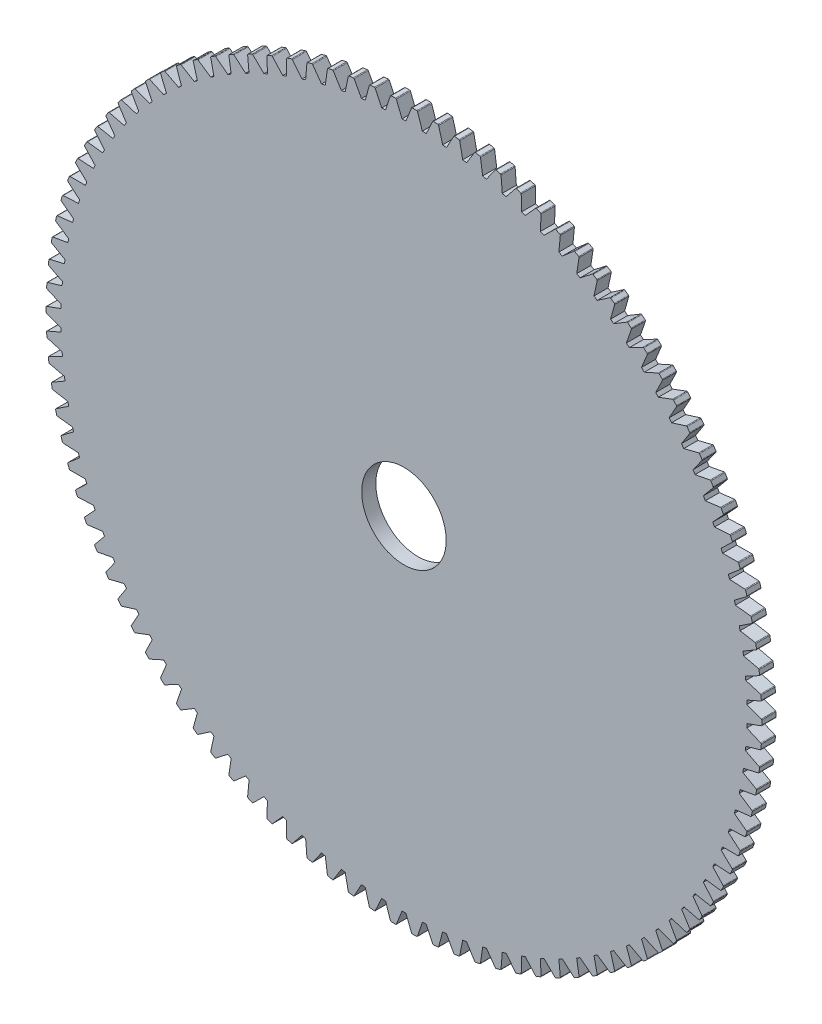
from build123d import *

# Parameters (mm, degrees)
MODEL_R             = 6
BOSS_EXTRUDE1_DEPTH = 2


with BuildPart() as part:
    # Model → Boss-Extrude1 (new body)
    with BuildSketch(Plane.XY):
        with BuildLine():
            Line((102.338378863, 52.221932874), (104.377671973, 52.964174865))
            ThreePointArc((104.377671973, 52.964174865), (104.43377915, 53.007227416), (104.45504553, 53.074675756))
            Line((104.45504553, 53.074675756), (104.45504553, 53.702906161))
            ThreePointArc((104.45504553, 53.702906161), (104.43377915, 53.770354502), (104.377671973, 53.813407053))
            Line((104.377671973, 53.813407053), (102.338378863, 54.555649044))
            ThreePointArc((102.338378863, 54.555649044), (102.330974591, 54.831854463), (102.322003277, 55.108013425))
            Line((102.322003277, 55.108013425), (104.313743959, 55.969760844))
            ThreePointArc((104.313743959, 55.969760844), (104.367202137, 56.016061607), (104.384435485, 56.084651324))
            Line((104.384435485, 56.084651324), (104.347218722, 56.711778388))
            ThreePointArc((104.347218722, 56.711778388), (104.321994009, 56.777848437), (104.263434911, 56.817501552))
            Line((104.263434911, 56.817501552), (102.183752466, 57.437630962))
            ThreePointArc((102.183752466, 57.437630962), (102.159998615, 57.712912657), (102.134683227, 57.988055143))
            Line((102.134683227, 57.988055143), (104.07187542, 58.966281071))
            ThreePointArc((104.07187542, 58.966281071), (104.122496824, 59.015667415), (104.135636608, 59.085157584))
            Line((104.135636608, 59.085157584), (104.061333806, 59.7089785))
            ThreePointArc((104.061333806, 59.7089785), (104.032239364, 59.773438184), (103.971434036, 59.80955258))
            Line((103.971434036, 59.80955258), (101.858667215, 60.305391183))
            ThreePointArc((101.858667215, 60.305391183), (101.818647222, 60.578782216), (101.777076681, 60.851941779))
            Line((101.777076681, 60.851941779), (103.652915926, 61.943210162))
            ThreePointArc((103.652915926, 61.943210162), (103.700522748, 61.995508613), (103.709522814, 62.065655148))
            Line((103.709522814, 62.065655148), (103.598394965, 62.683978722))
            ThreePointArc((103.598394965, 62.683978722), (103.565532988, 62.746601625), (103.502695011, 62.779050449))
            Line((103.502695011, 62.779050449), (101.364264985, 63.148856593))
            ThreePointArc((101.364264985, 63.148856593), (101.308119422, 63.419396669), (101.250439745, 63.689613825))
            Line((101.250439745, 63.689613825), (103.05833709, 64.890091543))
            ThreePointArc((103.05833709, 64.890091543), (103.102762108, 64.945118402), (103.107590843, 65.01567491))
            Line((103.107590843, 65.01567491), (102.960028287, 65.626329259))
            ThreePointArc((102.960028287, 65.626329259), (102.923514205, 65.686895415), (102.858864299, 65.715564689))
            Line((102.858864299, 65.715564689), (100.702282382, 65.958039417))
            ThreePointArc((100.702282382, 65.958039417), (100.630208461, 66.224778253), (100.556622252, 66.491103855))
            Line((100.556622252, 66.491103855), (102.29022739, 67.796574186))
            ThreePointArc((102.29022739, 67.796574186), (102.331314561, 67.854136169), (102.331955003, 67.924854818))
            Line((102.331955003, 67.924854818), (102.14847606, 68.525694996))
            ThreePointArc((102.14847606, 68.525694996), (102.108438128, 68.583991665), (102.04220338, 68.608780686))
            Line((102.04220338, 68.608780686), (99.875044644, 68.723072297))
            ThreePointArc((99.875044644, 68.723072297), (99.787295528, 68.985072964), (99.69806126, 69.246571534))
            Line((99.69806126, 69.246571534), (101.35128484, 70.652448965))
            ThreePointArc((101.35128484, 70.652448965), (101.388889842, 70.712343884), (101.385339743, 70.782976272))
            Line((101.385339743, 70.782976272), (101.166588888, 71.371891806))
            ThreePointArc((101.166588888, 71.371891806), (101.123167743, 71.427714218), (101.055580803, 71.448535915))
            Line((101.055580803, 71.448535915), (98.885457473, 71.434242954))
            ThreePointArc((98.885457473, 71.434242954), (98.782341384, 71.690585165), (98.677772495, 71.946338179))
            Line((98.677772495, 71.946338179), (100.24480751, 73.447684516))
            ThreePointArc((100.24480751, 73.447684516), (100.278798255, 73.509701987), (100.271070083, 73.580000016))
            Line((100.271070083, 73.580000016), (100.017815688, 74.154922318))
            ThreePointArc((100.017815688, 74.154922318), (99.971163848, 74.208074394), (99.902462118, 74.22485563))
            Line((99.902462118, 74.22485563), (97.73699683, 74.082028304))
            ThreePointArc((97.73699683, 74.082028304), (97.618875967, 74.331811647), (97.499339761, 74.580920763))
            Line((97.499339761, 74.580920763), (98.974681942, 76.172462471))
            ThreePointArc((98.974681942, 76.172462471), (99.004939036, 76.236384656), (98.993059938, 76.306101401))
            Line((98.993059938, 76.306101401), (98.706191567, 76.865011036))
            ThreePointArc((98.706191567, 76.865011036), (98.656472897, 76.915306079), (98.586897695, 76.927987909))
            Line((98.586897695, 76.927987909), (96.433696726, 76.657127902))
            ThreePointArc((96.433696726, 76.657127902), (96.300985993, 76.899475004), (96.166902343, 77.141065219))
            Line((96.166902343, 77.141065219), (97.545369498, 78.81721195))
            ThreePointArc((97.545369498, 78.81721195), (97.571786662, 78.882814319), (97.555798363, 78.951704898))
            Line((97.555798363, 78.951704898), (97.236323652, 79.492638675))
            ThreePointArc((97.236323652, 79.492638675), (97.183712792, 79.539900021), (97.113508503, 79.5484379))
            Line((97.113508503, 79.5484379), (94.980135049, 79.150496618))
            ThreePointArc((94.980135049, 79.150496618), (94.833300597, 79.384556227), (94.685140478, 79.617778944))
            Line((94.685140478, 79.617778944), (95.96189069, 81.372643172))
            ThreePointArc((95.96189069, 81.372643172), (95.984375133, 81.439695296), (95.964333793, 81.507517727))
            Line((95.964333793, 81.507517727), (95.613374909, 82.028575597))
            ThreePointArc((95.613374909, 82.028575597), (95.558056655, 82.072637239), (95.487469875, 82.077001177))
            Line((95.487469875, 82.077001177), (93.381417488, 81.553376404))
            ThreePointArc((93.381417488, 81.553376404), (93.220975079, 81.778326376), (93.059258909, 82.002362393))
            Line((93.059258909, 82.002362393), (94.229807546, 83.829780092))
            ThreePointArc((94.229807546, 83.829780092), (94.24828029, 83.898046447), (94.224256304, 83.964562503))
            Line((94.224256304, 83.964562503), (93.843046003, 84.46391423))
            ThreePointArc((93.843046003, 84.46391423), (93.785214664, 84.504621401), (93.71449333, 84.504796069))
            Line((93.71449333, 84.504796069), (91.643159597, 83.857327056))
            ThreePointArc((91.643159597, 83.857327056), (91.46967279, 84.072377246), (91.294968602, 84.286439629))
            Line((91.294968602, 84.286439629), (92.35520407, 86.179991929))
            ThreePointArc((92.35520407, 86.179991929), (92.36960023, 86.249232727), (92.341677984, 86.314208766))
            Line((92.341677984, 86.314208766), (91.93155528, 86.79010036))
            ThreePointArc((91.93155528, 86.79010036), (91.87141399, 86.827310073), (91.800806514, 86.823294858))
            Line((91.800806514, 86.823294858), (89.771467069, 86.054255863))
            ThreePointArc((89.771467069, 86.054255863), (89.585545243, 86.258650901), (89.398466693, 86.461987747))
            Line((89.398466693, 86.461987747), (90.344664876, 88.415023476))
            ThreePointArc((90.344664876, 88.415023476), (90.354933884, 88.484995506), (90.323211455, 88.548203298))
            Line((90.323211455, 88.548203298), (89.88561692, 88.998963173))
            ThreePointArc((89.88561692, 88.998963173), (89.823376928, 89.032544727), (89.753131322, 89.024353733))
            Line((89.753131322, 89.024353733), (87.772914294, 88.136446034))
            ThreePointArc((87.772914294, 88.136446034), (87.575210506, 88.329467973), (87.376414714, 88.521365055))
            Line((87.376414714, 88.521365055), (88.205252056, 90.527024103))
            ThreePointArc((88.205252056, 90.527024103), (88.211357842, 90.597481586), (88.175946657, 90.658699112))
            Line((88.175946657, 90.658699112), (87.712417357, 91.082743956))
            ThreePointArc((87.712417357, 91.082743956), (87.648297282, 91.112579397), (87.578660286, 91.100241394))
            Line((87.578660286, 91.100241394), (85.65452126, 90.096583799))
            ThreePointArc((85.65452126, 90.096583799), (85.445729952, 90.277554644), (85.235915196, 90.457337914))
            Line((85.235915196, 90.457337914), (85.944480376, 92.508575332))
            ThreePointArc((85.944480376, 92.508575332), (85.946401492, 92.579270784), (85.907425934, 92.638283014))
            Line((85.907425934, 92.638283014), (85.419590034, 93.034123356))
            ThreePointArc((85.419590034, 93.034123356), (85.3538151, 93.060107883), (85.285031317, 93.04366621))
            Line((85.285031317, 93.04366621), (83.423728901, 91.927784103))
            ThreePointArc((83.423728901, 91.927784103), (83.20458346, 92.096068186), (82.984486721, 92.263106151))
            Line((82.984486721, 92.263106151), (83.570290877, 94.352716892))
            ThreePointArc((83.570290877, 94.352716892), (83.568020577, 94.423401992), (83.525617549, 94.480001644))
            Line((83.525617549, 94.480001644), (83.015188589, 94.846247079))
            ThreePointArc((83.015188589, 94.846247079), (82.947989834, 94.868289422), (82.880300868, 94.847801831))
            Line((82.880300868, 94.847801831), (81.088372956, 93.623614788))
            ThreePointArc((81.088372956, 93.623614788), (80.859643138, 93.778621005), (80.630037514, 93.932326938))
            Line((80.630037514, 93.932326938), (81.091022989, 96.052971168))
            ThreePointArc((81.091022989, 96.052971168), (81.084569247, 96.123397632), (81.03888769, 96.177385898))
            Line((81.03888769, 96.177385898), (80.507658571, 96.512749975))
            ThreePointArc((80.507658571, 96.512749975), (80.439272033, 96.53077271), (80.372915645, 96.506311164))
            Line((80.372915645, 96.506311164), (78.656656447, 95.178119187))
            ThreePointArc((78.656656447, 95.178119187), (78.419145675, 95.319303074), (78.180837664, 95.459137076))
            Line((78.180837664, 95.459137076), (78.515385229, 97.603365955))
            ThreePointArc((78.515385229, 97.603365955), (78.504770713, 97.673286407), (78.455971087, 97.724473652))
            Line((78.455971087, 97.724473652), (77.90580777, 98.027778393))
            ThreePointArc((77.90580777, 98.027778393), (77.836473659, 98.041718214), (77.771682928, 98.013368634))
            Line((77.771682928, 98.013368634), (76.137120869, 96.585837046))
            ThreePointArc((76.137120869, 96.585837046), (75.891663407, 96.712702689), (75.645490074, 96.838173589))
            Line((75.645490074, 96.838173589), (75.852424619, 98.998455435))
            ThreePointArc((75.852424619, 98.998455435), (75.837686614, 99.067624277), (75.785940329, 99.115830703))
            Line((75.785940329, 99.115830703), (75.218775282, 99.386010739))
            ThreePointArc((75.218775282, 99.386010739), (75.148737137, 99.395818682), (75.085739643, 99.363680648))
            Line((75.085739643, 99.363680648), (73.538616181, 97.841823706))
            ThreePointArc((73.538616181, 97.841823706), (73.286074208, 97.953925484), (73.032900246, 98.064592561))
            Line((73.032900246, 98.064592561), (73.111494906, 100.233339305))
            ThreePointArc((73.111494906, 100.233339305), (73.092685179, 100.301513579), (73.038173995, 100.346569859))
            Line((73.038173995, 100.346569859), (72.455999408, 100.582676173))
            ThreePointArc((72.455999408, 100.582676173), (72.38550324, 100.588317787), (72.324520263, 100.552504185))
            Line((72.324520263, 100.552504185), (70.870269725, 98.941667467))
            ThreePointArc((70.870269725, 98.941667467), (70.611530304, 99.038611619), (70.352244997, 99.134086151))
            Line((70.352244997, 99.134086151), (70.302223704, 101.30367999))
            ThreePointArc((70.302223704, 101.30367999), (70.279408325, 101.370620232), (70.222323716, 101.412368105))
            Line((70.222323716, 101.412368105), (69.627184497, 101.613571365))
            ThreePointArc((69.627184497, 101.613571365), (69.556477926, 101.615026833), (69.497723672, 101.575663459))
            Line((69.497723672, 101.575663459), (68.141454167, 99.881505087))
            ThreePointArc((68.141454167, 99.881505087), (67.87742613, 99.962951094), (67.612940226, 100.042897722))
            Line((67.612940226, 100.042897722), (67.434478682, 102.205717881))
            ThreePointArc((67.434478682, 102.205717881), (67.407737791, 102.27118896), (67.348280267, 102.309481784))
            Line((67.348280267, 102.309481784), (66.742266865, 102.475075256))
            ThreePointArc((66.742266865, 102.475075256), (66.671598251, 102.472339466), (66.615279097, 102.429564586))
            Line((66.615279097, 102.429564586), (65.36175457, 100.658035354))
            ThreePointArc((65.36175457, 100.658035354), (65.093365324, 100.723697133), (64.82460784, 100.787835042))
            Line((64.82460784, 100.787835042), (64.518332899, 102.936284534))
            ThreePointArc((64.518332899, 102.936284534), (64.487760424, 103.000056482), (64.426138833, 103.034759752))
            Line((64.426138833, 103.034759752), (63.811379891, 103.164161783))
            ThreePointArc((63.811379891, 103.164161783), (63.740997461, 103.157244345), (63.687311228, 103.111208207))
            Line((63.687311228, 103.111208207), (62.540934731, 101.268530676))
            ThreePointArc((62.540934731, 101.268530676), (62.269127003, 101.318177588), (61.99704196, 101.366281491))
            Line((61.99704196, 101.366281491), (61.564029423, 103.49281381))
            ThreePointArc((61.564029423, 103.49281381), (61.529732751, 103.554662624), (61.46616354, 103.585654445))
            Line((61.46616354, 103.585654445), (60.844818423, 103.678410505))
            ThreePointArc((60.844818423, 103.678410505), (60.774969396, 103.667335716), (60.72410466, 103.618200025))
            Line((60.72410466, 103.618200025), (59.688902882, 101.710846665))
            ThreePointArc((59.688902882, 101.710846665), (59.414631407, 101.744304323), (59.140174512, 101.776205255))
            Line((59.140174512, 101.776205255), (58.581945352, 103.873350878))
            ThreePointArc((58.581945352, 103.873350878), (58.544044952, 103.933059313), (58.47875141, 103.960230823))
            Line((58.47875141, 103.960230823), (57.853002614, 104.016015104))
            ThreePointArc((57.853002614, 104.016015104), (57.783932338, 104.000821866), (57.736067764, 103.94875921))
            Line((57.736067764, 103.94875921), (56.815676889, 101.983429672))
            ThreePointArc((56.815676889, 101.983429672), (56.539905056, 102.000580555), (56.264040349, 102.016166461))
            Line((56.264040349, 102.016166461), (55.582555365, 104.076559088))
            ThreePointArc((55.582555365, 104.076559088), (55.541184364, 104.133917415), (55.474395838, 104.157173175))
            Line((55.474395838, 104.157173175), (54.846441329, 104.175789732))
            ThreePointArc((54.846441329, 104.175789732), (54.778392416, 104.156531411), (54.733696129, 104.101724664))
            Line((54.733696129, 104.101724664), (53.931349063, 102.085322238))
            ThreePointArc((53.931349063, 102.085322238), (53.65504553, 102.086106103), (53.378741997, 102.085322238))
            Line((53.378741997, 102.085322238), (52.576394931, 104.101724664))
            ThreePointArc((52.576394931, 104.101724664), (52.531698644, 104.156531411), (52.463649731, 104.175789732))
            Line((52.463649731, 104.175789732), (51.835695222, 104.157173175))
            ThreePointArc((51.835695222, 104.157173175), (51.768906696, 104.133917415), (51.727535694, 104.076559088))
            Line((51.727535694, 104.076559088), (51.046050711, 102.016166461))
            ThreePointArc((51.046050711, 102.016166461), (50.770186004, 102.000580555), (50.494414171, 101.983429672))
            Line((50.494414171, 101.983429672), (49.574023295, 103.94875921))
            ThreePointArc((49.574023295, 103.94875921), (49.526158721, 104.000821866), (49.457088446, 104.016015104))
            Line((49.457088446, 104.016015104), (48.83133965, 103.960230823))
            ThreePointArc((48.83133965, 103.960230823), (48.766046108, 103.933059313), (48.728145708, 103.873350878))
            Line((48.728145708, 103.873350878), (48.169916548, 101.776205255))
            ThreePointArc((48.169916548, 101.776205255), (47.895459653, 101.744304323), (47.621188178, 101.710846665))
            Line((47.621188178, 101.710846665), (46.5859864, 103.618200025))
            ThreePointArc((46.5859864, 103.618200025), (46.535121664, 103.667335716), (46.465272637, 103.678410505))
            Line((46.465272637, 103.678410505), (45.84392752, 103.585654445))
            ThreePointArc((45.84392752, 103.585654445), (45.780358309, 103.554662624), (45.746061637, 103.49281381))
            Line((45.746061637, 103.49281381), (45.3130491, 101.366281491))
            ThreePointArc((45.3130491, 101.366281491), (45.040964056, 101.318177588), (44.769156329, 101.268530676))
            Line((44.769156329, 101.268530676), (43.622779832, 103.111208207))
            ThreePointArc((43.622779832, 103.111208207), (43.569093599, 103.157244345), (43.498711169, 103.164161783))
            Line((43.498711169, 103.164161783), (42.883952227, 103.034759752))
            ThreePointArc((42.883952227, 103.034759752), (42.822330636, 103.000056482), (42.791758161, 102.936284534))
            Line((42.791758161, 102.936284534), (42.48548322, 100.787835042))
            ThreePointArc((42.48548322, 100.787835042), (42.216725736, 100.723697133), (41.948336489, 100.658035354))
            Line((41.948336489, 100.658035354), (40.694811963, 102.429564586))
            ThreePointArc((40.694811963, 102.429564586), (40.638492808, 102.472339466), (40.567824195, 102.475075256))
            Line((40.567824195, 102.475075256), (39.961810793, 102.309481784))
            ThreePointArc((39.961810793, 102.309481784), (39.902353268, 102.27118896), (39.875612377, 102.205717881))
            Line((39.875612377, 102.205717881), (39.697150834, 100.042897722))
            ThreePointArc((39.697150834, 100.042897722), (39.43266493, 99.962951094), (39.168636893, 99.881505087))
            Line((39.168636893, 99.881505087), (37.812367388, 101.575663459))
            ThreePointArc((37.812367388, 101.575663459), (37.753613134, 101.615026833), (37.682906563, 101.613571365))
            Line((37.682906563, 101.613571365), (37.087767344, 101.412368105))
            ThreePointArc((37.087767344, 101.412368105), (37.030682734, 101.370620232), (37.007867355, 101.30367999))
            Line((37.007867355, 101.30367999), (36.957846063, 99.134086151))
            ThreePointArc((36.957846063, 99.134086151), (36.698560756, 99.038611619), (36.439821335, 98.941667467))
            Line((36.439821335, 98.941667467), (34.985570797, 100.552504185))
            ThreePointArc((34.985570797, 100.552504185), (34.92458782, 100.588317787), (34.854091652, 100.582676173))
            Line((34.854091652, 100.582676173), (34.271917065, 100.346569859))
            ThreePointArc((34.271917065, 100.346569859), (34.217405881, 100.301513579), (34.198596154, 100.233339305))
            Line((34.198596154, 100.233339305), (34.277190814, 98.064592561))
            ThreePointArc((34.277190814, 98.064592561), (34.024016852, 97.953925484), (33.771474879, 97.841823706))
            Line((33.771474879, 97.841823706), (32.224351417, 99.363680648))
            ThreePointArc((32.224351417, 99.363680648), (32.161353923, 99.395818682), (32.091315777, 99.386010739))
            Line((32.091315777, 99.386010739), (31.524150731, 99.115830703))
            ThreePointArc((31.524150731, 99.115830703), (31.472404446, 99.067624277), (31.457666441, 98.998455435))
            Line((31.457666441, 98.998455435), (31.664600986, 96.838173589))
            ThreePointArc((31.664600986, 96.838173589), (31.418427653, 96.712702689), (31.172970191, 96.585837046))
            Line((31.172970191, 96.585837046), (29.538408132, 98.013368634))
            ThreePointArc((29.538408132, 98.013368634), (29.473617401, 98.041718214), (29.40428329, 98.027778393))
            Line((29.40428329, 98.027778393), (28.854119973, 97.724473652))
            ThreePointArc((28.854119973, 97.724473652), (28.805320347, 97.673286407), (28.794705831, 97.603365955))
            Line((28.794705831, 97.603365955), (29.129253396, 95.459137076))
            ThreePointArc((29.129253396, 95.459137076), (28.890945385, 95.319303074), (28.653434612, 95.178119187))
            Line((28.653434612, 95.178119187), (26.937175415, 96.506311164))
            ThreePointArc((26.937175415, 96.506311164), (26.870819027, 96.53077271), (26.802432489, 96.512749975))
            Line((26.802432489, 96.512749975), (26.27120337, 96.177385898))
            ThreePointArc((26.27120337, 96.177385898), (26.225521813, 96.123397632), (26.219068071, 96.052971168))
            Line((26.219068071, 96.052971168), (26.680053546, 93.932326938))
            ThreePointArc((26.680053546, 93.932326938), (26.450447921, 93.778621005), (26.221718104, 93.623614788))
            Line((26.221718104, 93.623614788), (24.429790192, 94.847801831))
            ThreePointArc((24.429790192, 94.847801831), (24.362101226, 94.868289422), (24.294902471, 94.846247079))
            Line((24.294902471, 94.846247079), (23.784473511, 94.480001644))
            ThreePointArc((23.784473511, 94.480001644), (23.742070483, 94.423401992), (23.739800182, 94.352716892))
            Line((23.739800182, 94.352716892), (24.325604339, 92.263106151))
            ThreePointArc((24.325604339, 92.263106151), (24.1055076, 92.096068186), (23.886362159, 91.927784103))
            Line((23.886362159, 91.927784103), (22.025059743, 93.04366621))
            ThreePointArc((22.025059743, 93.04366621), (21.95627596, 93.060107883), (21.890501026, 93.034123356))
            Line((21.890501026, 93.034123356), (21.402665126, 92.638283014))
            ThreePointArc((21.402665126, 92.638283014), (21.363689567, 92.579270784), (21.365610684, 92.508575332))
            Line((21.365610684, 92.508575332), (22.074175864, 90.457337914))
            ThreePointArc((22.074175864, 90.457337914), (21.864361107, 90.277554644), (21.6555698, 90.096583799))
            Line((21.6555698, 90.096583799), (19.731430774, 91.100241394))
            ThreePointArc((19.731430774, 91.100241394), (19.661793778, 91.112579397), (19.597673703, 91.082743956))
            Line((19.597673703, 91.082743956), (19.134144403, 90.658699112))
            ThreePointArc((19.134144403, 90.658699112), (19.098733218, 90.597481586), (19.104839004, 90.527024103))
            Line((19.104839004, 90.527024103), (19.933676346, 88.521365055))
            ThreePointArc((19.933676346, 88.521365055), (19.734880554, 88.329467973), (19.537176766, 88.136446034))
            Line((19.537176766, 88.136446034), (17.556959738, 89.024353733))
            ThreePointArc((17.556959738, 89.024353733), (17.486714132, 89.032544727), (17.42447414, 88.998963173))
            Line((17.42447414, 88.998963173), (16.986879605, 88.548203298))
            ThreePointArc((16.986879605, 88.548203298), (16.955157176, 88.484995506), (16.965426184, 88.415023476))
            Line((16.965426184, 88.415023476), (17.911624366, 86.461987747))
            ThreePointArc((17.911624366, 86.461987747), (17.724545817, 86.258650901), (17.538623991, 86.054255863))
            Line((17.538623991, 86.054255863), (15.509284545, 86.823294858))
            ThreePointArc((15.509284545, 86.823294858), (15.43867707, 86.827310073), (15.37853578, 86.79010036))
            Line((15.37853578, 86.79010036), (14.968413076, 86.314208766))
            ThreePointArc((14.968413076, 86.314208766), (14.94049083, 86.249232727), (14.95488699, 86.179991929))
            Line((14.95488699, 86.179991929), (16.015122458, 84.286439629))
            ThreePointArc((16.015122458, 84.286439629), (15.84041827, 84.072377246), (15.666931463, 83.857327056))
            Line((15.666931463, 83.857327056), (13.595597729, 84.504796069))
            ThreePointArc((13.595597729, 84.504796069), (13.524876396, 84.504621401), (13.467045057, 84.46391423))
            Line((13.467045057, 84.46391423), (13.085834755, 83.964562503))
            ThreePointArc((13.085834755, 83.964562503), (13.061810769, 83.898046447), (13.080283514, 83.829780092))
            Line((13.080283514, 83.829780092), (14.250832151, 82.002362393))
            ThreePointArc((14.250832151, 82.002362393), (14.089115981, 81.778326376), (13.928673572, 81.553376404))
            Line((13.928673572, 81.553376404), (11.822621185, 82.077001177))
            ThreePointArc((11.822621185, 82.077001177), (11.752034405, 82.072637239), (11.696716151, 82.028575597))
            Line((11.696716151, 82.028575597), (11.345757267, 81.507517727))
            ThreePointArc((11.345757267, 81.507517727), (11.325715926, 81.439695296), (11.34820037, 81.372643172))
            Line((11.34820037, 81.372643172), (12.624950581, 79.617778944))
            ThreePointArc((12.624950581, 79.617778944), (12.476790463, 79.384556227), (12.329956011, 79.150496618))
            Line((12.329956011, 79.150496618), (10.196582557, 79.5484379))
            ThreePointArc((10.196582557, 79.5484379), (10.126378268, 79.539900021), (10.073767407, 79.492638675))
            Line((10.073767407, 79.492638675), (9.754292697, 78.951704898))
            ThreePointArc((9.754292697, 78.951704898), (9.738304398, 78.882814319), (9.764721562, 78.81721195))
            Line((9.764721562, 78.81721195), (11.143188717, 77.141065219))
            ThreePointArc((11.143188717, 77.141065219), (11.009105067, 76.899475004), (10.876394334, 76.657127902))
            Line((10.876394334, 76.657127902), (8.723193364, 76.927987909))
            ThreePointArc((8.723193364, 76.927987909), (8.653618163, 76.915306079), (8.603899493, 76.865011036))
            Line((8.603899493, 76.865011036), (8.317031122, 76.306101401))
            ThreePointArc((8.317031122, 76.306101401), (8.305152024, 76.236384656), (8.335409118, 76.172462471))
            Line((8.335409118, 76.172462471), (9.810751299, 74.580920763))
            ThreePointArc((9.810751299, 74.580920763), (9.691215093, 74.331811647), (9.57309423, 74.082028304))
            Line((9.57309423, 74.082028304), (7.407628942, 74.22485563))
            ThreePointArc((7.407628942, 74.22485563), (7.338927212, 74.208074394), (7.292275372, 74.154922318))
            Line((7.292275372, 74.154922318), (7.039020976, 73.580000016))
            ThreePointArc((7.039020976, 73.580000016), (7.031292805, 73.509701987), (7.06528355, 73.447684516))
            Line((7.06528355, 73.447684516), (8.632318565, 71.946338179))
            ThreePointArc((8.632318565, 71.946338179), (8.527749676, 71.690585165), (8.424633587, 71.434242954))
            Line((8.424633587, 71.434242954), (6.254510256, 71.448535915))
            ThreePointArc((6.254510256, 71.448535915), (6.186923317, 71.427714218), (6.143502172, 71.371891806))
            Line((6.143502172, 71.371891806), (5.924751317, 70.782976272))
            ThreePointArc((5.924751317, 70.782976272), (5.921201217, 70.712343884), (5.95880622, 70.652448965))
            Line((5.95880622, 70.652448965), (7.6120298, 69.246571534))
            ThreePointArc((7.6120298, 69.246571534), (7.522795532, 68.985072964), (7.435046416, 68.723072297))
            Line((7.435046416, 68.723072297), (5.26788768, 68.608780686))
            ThreePointArc((5.26788768, 68.608780686), (5.201652931, 68.583991665), (5.161615, 68.525694996))
            Line((5.161615, 68.525694996), (4.978136057, 67.924854818))
            ThreePointArc((4.978136057, 67.924854818), (4.978776499, 67.854136169), (5.01986367, 67.796574186))
            Line((5.01986367, 67.796574186), (6.753468808, 66.491103855))
            ThreePointArc((6.753468808, 66.491103855), (6.679882599, 66.224778253), (6.607808678, 65.958039417))
            Line((6.607808678, 65.958039417), (4.451226761, 65.715564689))
            ThreePointArc((4.451226761, 65.715564689), (4.386576855, 65.686895415), (4.350062772, 65.626329259))
            Line((4.350062772, 65.626329259), (4.202500217, 65.01567491))
            ThreePointArc((4.202500217, 65.01567491), (4.207328952, 64.945118402), (4.25175397, 64.890091543))
            Line((4.25175397, 64.890091543), (6.059651315, 63.689613825))
            ThreePointArc((6.059651315, 63.689613825), (6.001971638, 63.419396669), (5.945826075, 63.148856593))
            Line((5.945826075, 63.148856593), (3.807396049, 62.779050449))
            ThreePointArc((3.807396049, 62.779050449), (3.744558072, 62.746601625), (3.711696095, 62.683978722))
            Line((3.711696095, 62.683978722), (3.600568246, 62.065655148))
            ThreePointArc((3.600568246, 62.065655148), (3.609568312, 61.995508613), (3.657175133, 61.943210162))
            Line((3.657175133, 61.943210162), (5.533014379, 60.851941779))
            ThreePointArc((5.533014379, 60.851941779), (5.491443838, 60.578782216), (5.451423845, 60.305391183))
            Line((5.451423845, 60.305391183), (3.338657024, 59.80955258))
            ThreePointArc((3.338657024, 59.80955258), (3.277851696, 59.773438184), (3.248757253, 59.7089785))
            Line((3.248757253, 59.7089785), (3.174454451, 59.085157584))
            ThreePointArc((3.174454451, 59.085157584), (3.187594236, 59.015667415), (3.23821564, 58.966281071))
            Line((3.23821564, 58.966281071), (5.175407833, 57.988055143))
            ThreePointArc((5.175407833, 57.988055143), (5.150092445, 57.712912657), (5.126338594, 57.437630962))
            Line((5.126338594, 57.437630962), (3.046656149, 56.817501552))
            ThreePointArc((3.046656149, 56.817501552), (2.988097051, 56.777848437), (2.962872338, 56.711778388))
            Line((2.962872338, 56.711778388), (2.925655574, 56.084651324))
            ThreePointArc((2.925655574, 56.084651324), (2.942888923, 56.016061607), (2.996347101, 55.969760844))
            Line((2.996347101, 55.969760844), (4.988087783, 55.108013425))
            ThreePointArc((4.988087783, 55.108013425), (4.979116469, 54.831854463), (4.971712197, 54.555649044))
            Line((4.971712197, 54.555649044), (2.932419087, 53.813407053))
            ThreePointArc((2.932419087, 53.813407053), (2.87631191, 53.770354502), (2.85504553, 53.702906161))
            Line((2.85504553, 53.702906161), (2.85504553, 53.074675756))
            ThreePointArc((2.85504553, 53.074675756), (2.87631191, 53.007227416), (2.932419087, 52.964174865))
            Line((2.932419087, 52.964174865), (4.971712197, 52.221932874))
            ThreePointArc((4.971712197, 52.221932874), (4.979116469, 51.945727455), (4.988087783, 51.669568493))
            Line((4.988087783, 51.669568493), (2.996347101, 50.807821074))
            ThreePointArc((2.996347101, 50.807821074), (2.942888923, 50.76152031), (2.925655574, 50.692930594))
            Line((2.925655574, 50.692930594), (2.962872338, 50.06580353))
            ThreePointArc((2.962872338, 50.06580353), (2.988097051, 49.999733481), (3.046656149, 49.960080366))
            Line((3.046656149, 49.960080366), (5.126338594, 49.339950955))
            ThreePointArc((5.126338594, 49.339950955), (5.150092445, 49.064669261), (5.175407833, 48.789526774))
            Line((5.175407833, 48.789526774), (3.23821564, 47.811300846))
            ThreePointArc((3.23821564, 47.811300846), (3.187594236, 47.761914503), (3.174454451, 47.692424334))
            Line((3.174454451, 47.692424334), (3.248757253, 47.068603418))
            ThreePointArc((3.248757253, 47.068603418), (3.277851696, 47.004143734), (3.338657024, 46.968029338))
            Line((3.338657024, 46.968029338), (5.451423845, 46.472190735))
            ThreePointArc((5.451423845, 46.472190735), (5.491443838, 46.198799702), (5.533014379, 45.925640139))
            Line((5.533014379, 45.925640139), (3.657175133, 44.834371756))
            ThreePointArc((3.657175133, 44.834371756), (3.609568312, 44.782073305), (3.600568246, 44.71192677))
            Line((3.600568246, 44.71192677), (3.711696095, 44.093603195))
            ThreePointArc((3.711696095, 44.093603195), (3.744558072, 44.030980292), (3.807396049, 43.998531469))
            Line((3.807396049, 43.998531469), (5.945826075, 43.628725325))
            ThreePointArc((5.945826075, 43.628725325), (6.001971638, 43.358185249), (6.059651315, 43.087968093))
            Line((6.059651315, 43.087968093), (4.25175397, 41.887490375))
            ThreePointArc((4.25175397, 41.887490375), (4.207328952, 41.832463516), (4.202500217, 41.761907008))
            Line((4.202500217, 41.761907008), (4.350062772, 41.151252659))
            ThreePointArc((4.350062772, 41.151252659), (4.386576855, 41.090686502), (4.451226761, 41.062017229))
            Line((4.451226761, 41.062017229), (6.607808678, 40.819542501))
            ThreePointArc((6.607808678, 40.819542501), (6.679882599, 40.552803665), (6.753468808, 40.286478062))
            Line((6.753468808, 40.286478062), (5.01986367, 38.981007732))
            ThreePointArc((5.01986367, 38.981007732), (4.978776499, 38.923445749), (4.978136057, 38.852727099))
            Line((4.978136057, 38.852727099), (5.161615, 38.251886922))
            ThreePointArc((5.161615, 38.251886922), (5.201652931, 38.193590253), (5.26788768, 38.168801232))
            Line((5.26788768, 38.168801232), (7.435046416, 38.054509621))
            ThreePointArc((7.435046416, 38.054509621), (7.522795532, 37.792508954), (7.6120298, 37.531010384))
            Line((7.6120298, 37.531010384), (5.95880622, 36.125132953))
            ThreePointArc((5.95880622, 36.125132953), (5.921201217, 36.065238034), (5.924751317, 35.994605645))
            Line((5.924751317, 35.994605645), (6.143502172, 35.405690112))
            ThreePointArc((6.143502172, 35.405690112), (6.186923317, 35.3498677), (6.254510256, 35.329046003))
            Line((6.254510256, 35.329046003), (8.424633587, 35.343338963))
            ThreePointArc((8.424633587, 35.343338963), (8.527749676, 35.086996753), (8.632318565, 34.831243739))
            Line((8.632318565, 34.831243739), (7.06528355, 33.329897402))
            ThreePointArc((7.06528355, 33.329897402), (7.031292805, 33.267879931), (7.039020976, 33.197581902))
            Line((7.039020976, 33.197581902), (7.292275372, 32.6226596))
            ThreePointArc((7.292275372, 32.6226596), (7.338927212, 32.569507523), (7.407628942, 32.552726287))
            Line((7.407628942, 32.552726287), (9.57309423, 32.695553614))
            ThreePointArc((9.57309423, 32.695553614), (9.691215093, 32.445770271), (9.810751299, 32.196661154))
            Line((9.810751299, 32.196661154), (8.335409118, 30.605119447))
            ThreePointArc((8.335409118, 30.605119447), (8.305152024, 30.541197262), (8.317031122, 30.471480517))
            Line((8.317031122, 30.471480517), (8.603899493, 29.912570882))
            ThreePointArc((8.603899493, 29.912570882), (8.653618163, 29.862275839), (8.723193364, 29.849594009))
            Line((8.723193364, 29.849594009), (10.876394334, 30.120454016))
            ThreePointArc((10.876394334, 30.120454016), (11.009105067, 29.878106913), (11.143188717, 29.636516699))
            Line((11.143188717, 29.636516699), (9.764721562, 27.960369968))
            ThreePointArc((9.764721562, 27.960369968), (9.738304398, 27.894767598), (9.754292697, 27.82587702))
            Line((9.754292697, 27.82587702), (10.073767407, 27.284943243))
            ThreePointArc((10.073767407, 27.284943243), (10.126378268, 27.237681897), (10.196582557, 27.229144018))
            Line((10.196582557, 27.229144018), (12.329956011, 27.6270853))
            ThreePointArc((12.329956011, 27.6270853), (12.476790463, 27.393025691), (12.624950581, 27.159802973))
            Line((12.624950581, 27.159802973), (11.34820037, 25.404938746))
            ThreePointArc((11.34820037, 25.404938746), (11.325715926, 25.337886622), (11.345757267, 25.270064191))
            Line((11.345757267, 25.270064191), (11.696716151, 24.749006321))
            ThreePointArc((11.696716151, 24.749006321), (11.752034405, 24.704944679), (11.822621185, 24.700580741))
            Line((11.822621185, 24.700580741), (13.928673572, 25.224205514))
            ThreePointArc((13.928673572, 25.224205514), (14.089115981, 24.999255542), (14.250832151, 24.775219524))
            Line((14.250832151, 24.775219524), (13.080283514, 22.947801825))
            ThreePointArc((13.080283514, 22.947801825), (13.061810769, 22.87953547), (13.085834755, 22.813019415))
            Line((13.085834755, 22.813019415), (13.467045057, 22.313667688))
            ThreePointArc((13.467045057, 22.313667688), (13.524876396, 22.272960517), (13.595597729, 22.272785849))
            Line((13.595597729, 22.272785849), (15.666931463, 22.920254862))
            ThreePointArc((15.666931463, 22.920254862), (15.84041827, 22.705204672), (16.015122458, 22.491142289))
            Line((16.015122458, 22.491142289), (14.95488699, 20.597589989))
            ThreePointArc((14.95488699, 20.597589989), (14.94049083, 20.528349191), (14.968413076, 20.463373152))
            Line((14.968413076, 20.463373152), (15.37853578, 19.987481558))
            ThreePointArc((15.37853578, 19.987481558), (15.43867707, 19.950271845), (15.509284545, 19.95428706))
            Line((15.509284545, 19.95428706), (17.538623991, 20.723326054))
            ThreePointArc((17.538623991, 20.723326054), (17.724545817, 20.518931017), (17.911624366, 20.315594171))
            Line((17.911624366, 20.315594171), (16.965426184, 18.362558442))
            ThreePointArc((16.965426184, 18.362558442), (16.955157176, 18.292586412), (16.986879605, 18.22937862))
            Line((16.986879605, 18.22937862), (17.42447414, 17.778618745))
            ThreePointArc((17.42447414, 17.778618745), (17.486714132, 17.74503719), (17.556959738, 17.753228185))
            Line((17.556959738, 17.753228185), (19.537176766, 18.641135884))
            ThreePointArc((19.537176766, 18.641135884), (19.734880554, 18.448113944), (19.933676346, 18.256216863))
            Line((19.933676346, 18.256216863), (19.104839004, 16.250557815))
            ThreePointArc((19.104839004, 16.250557815), (19.098733218, 16.180100332), (19.134144403, 16.118882806))
            Line((19.134144403, 16.118882806), (19.597673703, 15.694837961))
            ThreePointArc((19.597673703, 15.694837961), (19.661793778, 15.665002521), (19.731430774, 15.677340523))
            Line((19.731430774, 15.677340523), (21.6555698, 16.680998118))
            ThreePointArc((21.6555698, 16.680998118), (21.864361107, 16.500027274), (22.074175864, 16.320244003))
            Line((22.074175864, 16.320244003), (21.365610684, 14.269006585))
            ThreePointArc((21.365610684, 14.269006585), (21.363689567, 14.198311134), (21.402665126, 14.139298903))
            Line((21.402665126, 14.139298903), (21.890501026, 13.743458562))
            ThreePointArc((21.890501026, 13.743458562), (21.95627596, 13.717474035), (22.025059743, 13.733915707))
            Line((22.025059743, 13.733915707), (23.886362159, 14.849797815))
            ThreePointArc((23.886362159, 14.849797815), (24.1055076, 14.681513732), (24.325604339, 14.514475766))
            Line((24.325604339, 14.514475766), (23.739800182, 12.424865025))
            ThreePointArc((23.739800182, 12.424865025), (23.742070483, 12.354179926), (23.784473511, 12.297580273))
            Line((23.784473511, 12.297580273), (24.294902471, 11.931334839))
            ThreePointArc((24.294902471, 11.931334839), (24.362101226, 11.909292496), (24.429790192, 11.929780087))
            Line((24.429790192, 11.929780087), (26.221718104, 13.15396713))
            ThreePointArc((26.221718104, 13.15396713), (26.450447921, 12.998960912), (26.680053546, 12.845254979))
            Line((26.680053546, 12.845254979), (26.219068071, 10.724610749))
            ThreePointArc((26.219068071, 10.724610749), (26.225521813, 10.654184286), (26.27120337, 10.600196019))
            Line((26.27120337, 10.600196019), (26.802432489, 10.264831943))
            ThreePointArc((26.802432489, 10.264831943), (26.870819027, 10.246809208), (26.937175415, 10.271270754))
            Line((26.937175415, 10.271270754), (28.653434612, 11.599462731))
            ThreePointArc((28.653434612, 11.599462731), (28.890945385, 11.458278844), (29.129253396, 11.318444841))
            Line((29.129253396, 11.318444841), (28.794705831, 9.174215962))
            ThreePointArc((28.794705831, 9.174215962), (28.805320347, 9.104295511), (28.854119973, 9.053108266))
            Line((28.854119973, 9.053108266), (29.40428329, 8.749803525))
            ThreePointArc((29.40428329, 8.749803525), (29.473617401, 8.735863704), (29.538408132, 8.764213284))
            Line((29.538408132, 8.764213284), (31.172970191, 10.191744871))
            ThreePointArc((31.172970191, 10.191744871), (31.418427653, 10.064879229), (31.664600986, 9.939408328))
            Line((31.664600986, 9.939408328), (31.457666441, 7.779126483))
            ThreePointArc((31.457666441, 7.779126483), (31.472404446, 7.70995764), (31.524150731, 7.661751215))
            Line((31.524150731, 7.661751215), (32.091315777, 7.391571179))
            ThreePointArc((32.091315777, 7.391571179), (32.161353923, 7.381763236), (32.224351417, 7.41390127))
            Line((32.224351417, 7.41390127), (33.771474879, 8.935758212))
            ThreePointArc((33.771474879, 8.935758212), (34.024016852, 8.823656433), (34.277190814, 8.712989356))
            Line((34.277190814, 8.712989356), (34.198596154, 6.544242613))
            ThreePointArc((34.198596154, 6.544242613), (34.217405881, 6.476068338), (34.271917065, 6.431012058))
            Line((34.271917065, 6.431012058), (34.854091652, 6.194905744))
            ThreePointArc((34.854091652, 6.194905744), (34.92458782, 6.189264131), (34.985570797, 6.225077733))
            Line((34.985570797, 6.225077733), (36.439821335, 7.835914451))
            ThreePointArc((36.439821335, 7.835914451), (36.698560756, 7.738970298), (36.957846063, 7.643495767))
            Line((36.957846063, 7.643495767), (37.007867355, 5.473901927))
            ThreePointArc((37.007867355, 5.473901927), (37.030682734, 5.406961685), (37.087767344, 5.365213813))
            Line((37.087767344, 5.365213813), (37.682906563, 5.164010553))
            ThreePointArc((37.682906563, 5.164010553), (37.753613134, 5.162555085), (37.812367388, 5.201918459))
            Line((37.812367388, 5.201918459), (39.168636893, 6.89607683))
            ThreePointArc((39.168636893, 6.89607683), (39.43266493, 6.814630824), (39.697150834, 6.734684195))
            Line((39.697150834, 6.734684195), (39.875612377, 4.571864037))
            ThreePointArc((39.875612377, 4.571864037), (39.902353268, 4.506392958), (39.961810793, 4.468100134))
            Line((39.961810793, 4.468100134), (40.567824195, 4.302506662))
            ThreePointArc((40.567824195, 4.302506662), (40.638492808, 4.305242452), (40.694811963, 4.348017331))
            Line((40.694811963, 4.348017331), (41.948336489, 6.119546564))
            ThreePointArc((41.948336489, 6.119546564), (42.216725736, 6.053884785), (42.48548322, 5.989746875))
            Line((42.48548322, 5.989746875), (42.791758161, 3.841297383))
            ThreePointArc((42.791758161, 3.841297383), (42.822330636, 3.777525436), (42.883952227, 3.742822166))
            Line((42.883952227, 3.742822166), (43.498711169, 3.613420135))
            ThreePointArc((43.498711169, 3.613420135), (43.569093599, 3.620337573), (43.622779832, 3.66637371))
            Line((43.622779832, 3.66637371), (44.769156329, 5.509051242))
            ThreePointArc((44.769156329, 5.509051242), (45.040964056, 5.45940433), (45.3130491, 5.411300426))
            Line((45.3130491, 5.411300426), (45.746061637, 3.284768108))
            ThreePointArc((45.746061637, 3.284768108), (45.780358309, 3.222919293), (45.84392752, 3.191927473))
            Line((45.84392752, 3.191927473), (46.465272637, 3.099171413))
            ThreePointArc((46.465272637, 3.099171413), (46.535121664, 3.110246201), (46.5859864, 3.159381893))
            Line((46.5859864, 3.159381893), (47.621188178, 5.066735253))
            ThreePointArc((47.621188178, 5.066735253), (47.895459653, 5.033277594), (48.169916548, 5.001376663))
            Line((48.169916548, 5.001376663), (48.728145708, 2.90423104))
            ThreePointArc((48.728145708, 2.90423104), (48.766046108, 2.844522605), (48.83133965, 2.817351095))
            Line((48.83133965, 2.817351095), (49.457088446, 2.761566813))
            ThreePointArc((49.457088446, 2.761566813), (49.526158721, 2.776760052), (49.574023295, 2.828822707))
            Line((49.574023295, 2.828822707), (50.494414171, 4.794152246))
            ThreePointArc((50.494414171, 4.794152246), (50.770186004, 4.777001363), (51.046050711, 4.761415456))
            Line((51.046050711, 4.761415456), (51.727535694, 2.70102283))
            ThreePointArc((51.727535694, 2.70102283), (51.768906696, 2.643664502), (51.835695222, 2.620408743))
            Line((51.835695222, 2.620408743), (52.463649731, 2.601792185))
            ThreePointArc((52.463649731, 2.601792185), (52.531698644, 2.621050507), (52.576394931, 2.675857254))
            Line((52.576394931, 2.675857254), (53.378741997, 4.69225968))
            ThreePointArc((53.378741997, 4.69225968), (53.65504553, 4.691475815), (53.931349063, 4.69225968))
            Line((53.931349063, 4.69225968), (54.733696129, 2.675857254))
            ThreePointArc((54.733696129, 2.675857254), (54.778392416, 2.621050507), (54.846441329, 2.601792185))
            Line((54.846441329, 2.601792185), (55.474395838, 2.620408743))
            ThreePointArc((55.474395838, 2.620408743), (55.541184364, 2.643664502), (55.582555365, 2.70102283))
            Line((55.582555365, 2.70102283), (56.264040349, 4.761415456))
            ThreePointArc((56.264040349, 4.761415456), (56.539905056, 4.777001363), (56.815676889, 4.794152246))
            Line((56.815676889, 4.794152246), (57.736067764, 2.828822707))
            ThreePointArc((57.736067764, 2.828822707), (57.783932338, 2.776760052), (57.853002614, 2.761566813))
            Line((57.853002614, 2.761566813), (58.47875141, 2.817351095))
            ThreePointArc((58.47875141, 2.817351095), (58.544044952, 2.844522605), (58.581945352, 2.90423104))
            Line((58.581945352, 2.90423104), (59.140174512, 5.001376663))
            ThreePointArc((59.140174512, 5.001376663), (59.414631407, 5.033277594), (59.688902882, 5.066735253))
            Line((59.688902882, 5.066735253), (60.72410466, 3.159381893))
            ThreePointArc((60.72410466, 3.159381893), (60.774969396, 3.110246201), (60.844818423, 3.099171413))
            Line((60.844818423, 3.099171413), (61.46616354, 3.191927473))
            ThreePointArc((61.46616354, 3.191927473), (61.529732751, 3.222919293), (61.564029423, 3.284768108))
            Line((61.564029423, 3.284768108), (61.99704196, 5.411300426))
            ThreePointArc((61.99704196, 5.411300426), (62.269127003, 5.45940433), (62.540934731, 5.509051242))
            Line((62.540934731, 5.509051242), (63.687311228, 3.66637371))
            ThreePointArc((63.687311228, 3.66637371), (63.740997461, 3.620337573), (63.811379891, 3.613420135))
            Line((63.811379891, 3.613420135), (64.426138833, 3.742822166))
            ThreePointArc((64.426138833, 3.742822166), (64.487760424, 3.777525436), (64.518332899, 3.841297383))
            Line((64.518332899, 3.841297383), (64.82460784, 5.989746875))
            ThreePointArc((64.82460784, 5.989746875), (65.093365324, 6.053884785), (65.36175457, 6.119546564))
            Line((65.36175457, 6.119546564), (66.615279097, 4.348017331))
            ThreePointArc((66.615279097, 4.348017331), (66.671598251, 4.305242452), (66.742266865, 4.302506662))
            Line((66.742266865, 4.302506662), (67.348280267, 4.468100134))
            ThreePointArc((67.348280267, 4.468100134), (67.407737791, 4.506392958), (67.434478682, 4.571864037))
            Line((67.434478682, 4.571864037), (67.612940226, 6.734684195))
            ThreePointArc((67.612940226, 6.734684195), (67.87742613, 6.814630824), (68.141454167, 6.89607683))
            Line((68.141454167, 6.89607683), (69.497723672, 5.201918459))
            ThreePointArc((69.497723672, 5.201918459), (69.556477926, 5.162555085), (69.627184497, 5.164010553))
            Line((69.627184497, 5.164010553), (70.222323716, 5.365213813))
            ThreePointArc((70.222323716, 5.365213813), (70.279408325, 5.406961685), (70.302223704, 5.473901927))
            Line((70.302223704, 5.473901927), (70.352244997, 7.643495767))
            ThreePointArc((70.352244997, 7.643495767), (70.611530304, 7.738970298), (70.870269725, 7.835914451))
            Line((70.870269725, 7.835914451), (72.324520263, 6.225077733))
            ThreePointArc((72.324520263, 6.225077733), (72.38550324, 6.189264131), (72.455999408, 6.194905744))
            Line((72.455999408, 6.194905744), (73.038173995, 6.431012058))
            ThreePointArc((73.038173995, 6.431012058), (73.092685179, 6.476068338), (73.111494906, 6.544242613))
            Line((73.111494906, 6.544242613), (73.032900246, 8.712989356))
            ThreePointArc((73.032900246, 8.712989356), (73.286074208, 8.823656433), (73.538616181, 8.935758212))
            Line((73.538616181, 8.935758212), (75.085739643, 7.41390127))
            ThreePointArc((75.085739643, 7.41390127), (75.148737137, 7.381763236), (75.218775282, 7.391571179))
            Line((75.218775282, 7.391571179), (75.785940329, 7.661751215))
            ThreePointArc((75.785940329, 7.661751215), (75.837686614, 7.70995764), (75.852424619, 7.779126483))
            Line((75.852424619, 7.779126483), (75.645490074, 9.939408328))
            ThreePointArc((75.645490074, 9.939408328), (75.891663407, 10.064879229), (76.137120869, 10.191744871))
            Line((76.137120869, 10.191744871), (77.771682928, 8.764213284))
            ThreePointArc((77.771682928, 8.764213284), (77.836473659, 8.735863704), (77.90580777, 8.749803525))
            Line((77.90580777, 8.749803525), (78.455971087, 9.053108266))
            ThreePointArc((78.455971087, 9.053108266), (78.504770713, 9.104295511), (78.515385229, 9.174215962))
            Line((78.515385229, 9.174215962), (78.180837664, 11.318444841))
            ThreePointArc((78.180837664, 11.318444841), (78.419145675, 11.458278844), (78.656656447, 11.599462731))
            Line((78.656656447, 11.599462731), (80.372915645, 10.271270754))
            ThreePointArc((80.372915645, 10.271270754), (80.439272033, 10.246809208), (80.507658571, 10.264831943))
            Line((80.507658571, 10.264831943), (81.03888769, 10.600196019))
            ThreePointArc((81.03888769, 10.600196019), (81.084569247, 10.654184286), (81.091022989, 10.724610749))
            Line((81.091022989, 10.724610749), (80.630037514, 12.845254979))
            ThreePointArc((80.630037514, 12.845254979), (80.859643138, 12.998960912), (81.088372956, 13.15396713))
            Line((81.088372956, 13.15396713), (82.880300868, 11.929780087))
            ThreePointArc((82.880300868, 11.929780087), (82.947989834, 11.909292496), (83.015188589, 11.931334839))
            Line((83.015188589, 11.931334839), (83.525617549, 12.297580273))
            ThreePointArc((83.525617549, 12.297580273), (83.568020577, 12.354179926), (83.570290877, 12.424865025))
            Line((83.570290877, 12.424865025), (82.984486721, 14.514475766))
            ThreePointArc((82.984486721, 14.514475766), (83.20458346, 14.681513732), (83.423728901, 14.849797815))
            Line((83.423728901, 14.849797815), (85.285031317, 13.733915707))
            ThreePointArc((85.285031317, 13.733915707), (85.3538151, 13.717474035), (85.419590034, 13.743458562))
            Line((85.419590034, 13.743458562), (85.907425934, 14.139298903))
            ThreePointArc((85.907425934, 14.139298903), (85.946401492, 14.198311134), (85.944480376, 14.269006585))
            Line((85.944480376, 14.269006585), (85.235915196, 16.320244003))
            ThreePointArc((85.235915196, 16.320244003), (85.445729952, 16.500027274), (85.65452126, 16.680998118))
            Line((85.65452126, 16.680998118), (87.578660286, 15.677340523))
            ThreePointArc((87.578660286, 15.677340523), (87.648297282, 15.665002521), (87.712417357, 15.694837961))
            Line((87.712417357, 15.694837961), (88.175946657, 16.118882806))
            ThreePointArc((88.175946657, 16.118882806), (88.211357842, 16.180100332), (88.205252056, 16.250557815))
            Line((88.205252056, 16.250557815), (87.376414714, 18.256216863))
            ThreePointArc((87.376414714, 18.256216863), (87.575210506, 18.448113944), (87.772914294, 18.641135884))
            Line((87.772914294, 18.641135884), (89.753131322, 17.753228185))
            ThreePointArc((89.753131322, 17.753228185), (89.823376928, 17.74503719), (89.88561692, 17.778618745))
            Line((89.88561692, 17.778618745), (90.323211455, 18.22937862))
            ThreePointArc((90.323211455, 18.22937862), (90.354933884, 18.292586412), (90.344664876, 18.362558442))
            Line((90.344664876, 18.362558442), (89.398466693, 20.315594171))
            ThreePointArc((89.398466693, 20.315594171), (89.585545243, 20.518931017), (89.771467069, 20.723326054))
            Line((89.771467069, 20.723326054), (91.800806514, 19.95428706))
            ThreePointArc((91.800806514, 19.95428706), (91.87141399, 19.950271845), (91.93155528, 19.987481558))
            Line((91.93155528, 19.987481558), (92.341677984, 20.463373152))
            ThreePointArc((92.341677984, 20.463373152), (92.36960023, 20.528349191), (92.35520407, 20.597589989))
            Line((92.35520407, 20.597589989), (91.294968602, 22.491142289))
            ThreePointArc((91.294968602, 22.491142289), (91.46967279, 22.705204672), (91.643159597, 22.920254862))
            Line((91.643159597, 22.920254862), (93.71449333, 22.272785849))
            ThreePointArc((93.71449333, 22.272785849), (93.785214664, 22.272960517), (93.843046003, 22.313667688))
            Line((93.843046003, 22.313667688), (94.224256304, 22.813019415))
            ThreePointArc((94.224256304, 22.813019415), (94.24828029, 22.87953547), (94.229807546, 22.947801825))
            Line((94.229807546, 22.947801825), (93.059258909, 24.775219524))
            ThreePointArc((93.059258909, 24.775219524), (93.220975079, 24.999255542), (93.381417488, 25.224205514))
            Line((93.381417488, 25.224205514), (95.487469875, 24.700580741))
            ThreePointArc((95.487469875, 24.700580741), (95.558056655, 24.704944679), (95.613374909, 24.749006321))
            Line((95.613374909, 24.749006321), (95.964333793, 25.270064191))
            ThreePointArc((95.964333793, 25.270064191), (95.984375133, 25.337886622), (95.96189069, 25.404938746))
            Line((95.96189069, 25.404938746), (94.685140478, 27.159802973))
            ThreePointArc((94.685140478, 27.159802973), (94.833300597, 27.393025691), (94.980135049, 27.6270853))
            Line((94.980135049, 27.6270853), (97.113508503, 27.229144018))
            ThreePointArc((97.113508503, 27.229144018), (97.183712792, 27.237681897), (97.236323652, 27.284943243))
            Line((97.236323652, 27.284943243), (97.555798363, 27.82587702))
            ThreePointArc((97.555798363, 27.82587702), (97.571786662, 27.894767598), (97.545369498, 27.960369968))
            Line((97.545369498, 27.960369968), (96.166902343, 29.636516699))
            ThreePointArc((96.166902343, 29.636516699), (96.300985993, 29.878106913), (96.433696726, 30.120454016))
            Line((96.433696726, 30.120454016), (98.586897695, 29.849594009))
            ThreePointArc((98.586897695, 29.849594009), (98.656472897, 29.862275839), (98.706191567, 29.912570882))
            Line((98.706191567, 29.912570882), (98.993059938, 30.471480517))
            ThreePointArc((98.993059938, 30.471480517), (99.004939036, 30.541197262), (98.974681942, 30.605119447))
            Line((98.974681942, 30.605119447), (97.499339761, 32.196661154))
            ThreePointArc((97.499339761, 32.196661154), (97.618875967, 32.445770271), (97.73699683, 32.695553614))
            Line((97.73699683, 32.695553614), (99.902462118, 32.552726287))
            ThreePointArc((99.902462118, 32.552726287), (99.971163848, 32.569507523), (100.017815688, 32.6226596))
            Line((100.017815688, 32.6226596), (100.271070083, 33.197581902))
            ThreePointArc((100.271070083, 33.197581902), (100.278798255, 33.267879931), (100.24480751, 33.329897402))
            Line((100.24480751, 33.329897402), (98.677772495, 34.831243739))
            ThreePointArc((98.677772495, 34.831243739), (98.782341384, 35.086996753), (98.885457473, 35.343338963))
            Line((98.885457473, 35.343338963), (101.055580803, 35.329046003))
            ThreePointArc((101.055580803, 35.329046003), (101.123167743, 35.3498677), (101.166588888, 35.405690112))
            Line((101.166588888, 35.405690112), (101.385339743, 35.994605645))
            ThreePointArc((101.385339743, 35.994605645), (101.388889842, 36.065238034), (101.35128484, 36.125132953))
            Line((101.35128484, 36.125132953), (99.69806126, 37.531010384))
            ThreePointArc((99.69806126, 37.531010384), (99.787295528, 37.792508954), (99.875044644, 38.054509621))
            Line((99.875044644, 38.054509621), (102.04220338, 38.168801232))
            ThreePointArc((102.04220338, 38.168801232), (102.108438128, 38.193590253), (102.14847606, 38.251886922))
            Line((102.14847606, 38.251886922), (102.331955003, 38.852727099))
            ThreePointArc((102.331955003, 38.852727099), (102.331314561, 38.923445749), (102.29022739, 38.981007732))
            Line((102.29022739, 38.981007732), (100.556622252, 40.286478062))
            ThreePointArc((100.556622252, 40.286478062), (100.630208461, 40.552803665), (100.702282382, 40.819542501))
            Line((100.702282382, 40.819542501), (102.858864299, 41.062017229))
            ThreePointArc((102.858864299, 41.062017229), (102.923514205, 41.090686502), (102.960028287, 41.151252659))
            Line((102.960028287, 41.151252659), (103.107590843, 41.761907008))
            ThreePointArc((103.107590843, 41.761907008), (103.102762108, 41.832463516), (103.05833709, 41.887490375))
            Line((103.05833709, 41.887490375), (101.250439745, 43.087968093))
            ThreePointArc((101.250439745, 43.087968093), (101.308119422, 43.358185249), (101.364264985, 43.628725325))
            Line((101.364264985, 43.628725325), (103.502695011, 43.998531469))
            ThreePointArc((103.502695011, 43.998531469), (103.565532988, 44.030980292), (103.598394965, 44.093603195))
            Line((103.598394965, 44.093603195), (103.709522814, 44.71192677))
            ThreePointArc((103.709522814, 44.71192677), (103.700522748, 44.782073305), (103.652915926, 44.834371756))
            Line((103.652915926, 44.834371756), (101.777076681, 45.925640139))
            ThreePointArc((101.777076681, 45.925640139), (101.818647222, 46.198799702), (101.858667215, 46.472190735))
            Line((101.858667215, 46.472190735), (103.971434036, 46.968029338))
            ThreePointArc((103.971434036, 46.968029338), (104.032239364, 47.004143734), (104.061333806, 47.068603418))
            Line((104.061333806, 47.068603418), (104.135636608, 47.692424334))
            ThreePointArc((104.135636608, 47.692424334), (104.122496824, 47.761914503), (104.07187542, 47.811300846))
            Line((104.07187542, 47.811300846), (102.134683227, 48.789526774))
            ThreePointArc((102.134683227, 48.789526774), (102.159998615, 49.064669261), (102.183752466, 49.339950955))
            Line((102.183752466, 49.339950955), (104.263434911, 49.960080366))
            ThreePointArc((104.263434911, 49.960080366), (104.321994009, 49.999733481), (104.347218722, 50.06580353))
            Line((104.347218722, 50.06580353), (104.384435485, 50.692930594))
            ThreePointArc((104.384435485, 50.692930594), (104.367202137, 50.76152031), (104.313743959, 50.807821074))
            Line((104.313743959, 50.807821074), (102.322003277, 51.669568493))
            ThreePointArc((102.322003277, 51.669568493), (102.330974591, 51.945727455), (102.338378863, 52.221932874))
        make_face()
        with Locations((53.65504553, 53.388790959)):
            Circle(MODEL_R, mode=Mode.SUBTRACT)
    extrude(amount=BOSS_EXTRUDE1_DEPTH)


solid = part.part
